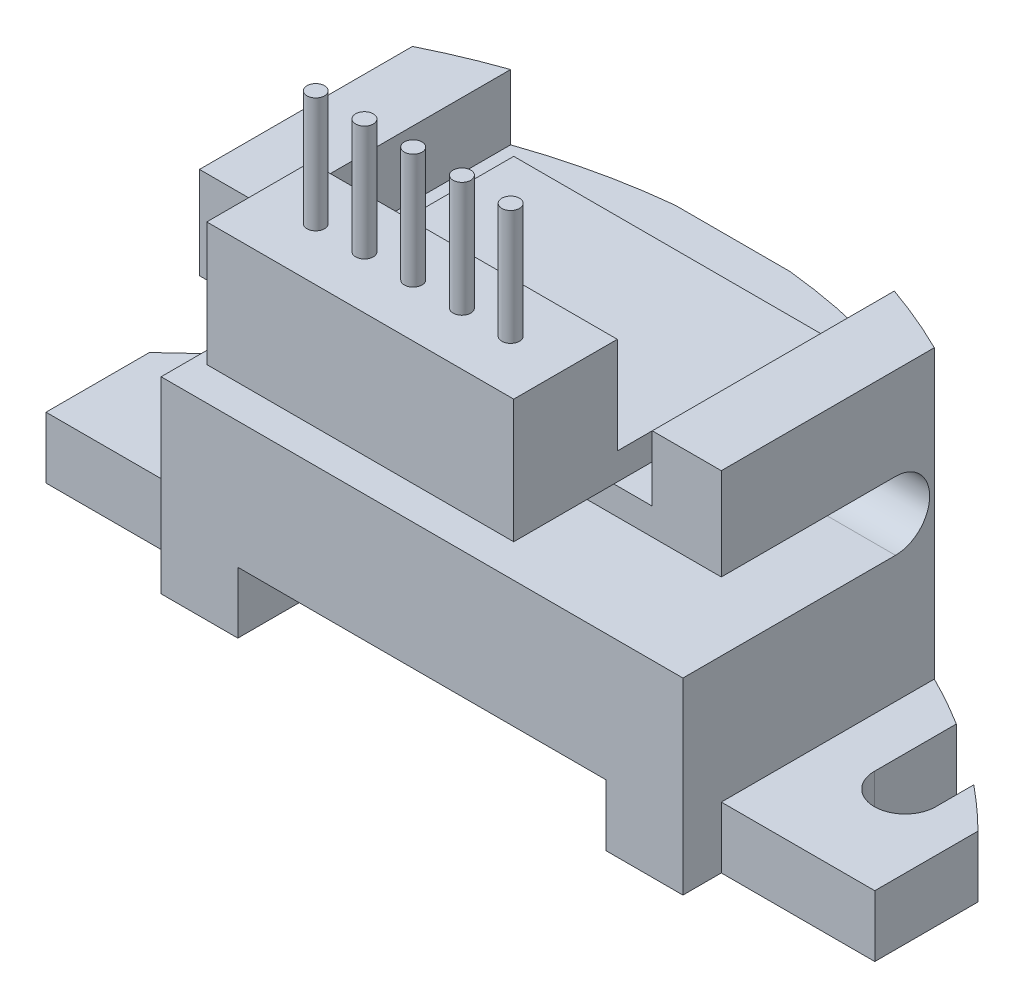
from build123d import *

# Parameters (mm, degrees)
BOSS_EXTRUDE1_DEPTH = 1.6
BOSS_EXTRUDE2_DEPTH = 1.6
BOSS_EXTRUDE3_DEPTH = 3.3
BOSS_EXTRUDE4_DEPTH = 1
BOSS_EXTRUDE5_DEPTH = 6.8
SKETCH7_W           = 1.5
SKETCH7_H           = 1.538953592
BOSS_EXTRUDE6_DEPTH = 4.18
SKETCH8_R           = 1
BOSS_EXTRUDE7_DEPTH = 0.8
SKETCH9_W           = 5
SKETCH9_H           = 1.7
CUT_EXTRUDE1_DEPTH  = 8.09
BOSS_EXTRUDE8_DEPTH = 4
SKETCH12_R          = 0.23
BOSS_EXTRUDE9_DEPTH = 3


with BuildPart() as part:
    # Sketch1 → Boss-Extrude1 (new body)
    with BuildSketch(Plane(origin=(0, 0, 0), x_dir=(1, 0, 0), z_dir=(0, 1, 0))):
        with BuildLine():
            Line((9.7, 0), (9.7, 0.989309127))
            ThreePointArc((9.7, 0.989309127), (10.261810116, 0.507786079), (10.8, 0))
            Line((10.8, 0), (10.8, -2.69))
            Line((10.8, -2.69), (6.8, -2.69))
            Line((6.8, -2.69), (6.8, 2.861046408))
            ThreePointArc((6.8, 2.861046408), (7.458731009, 2.513392708), (8.1, 2.134494679))
            Line((8.1, 2.134494679), (8.1, 0))
            ThreePointArc((8.1, 0), (8.9, -0.8), (9.7, 0))
        make_face()
    extrude(amount=BOSS_EXTRUDE1_DEPTH)

    # Sketch2 → Boss-Extrude2 (add)
    with BuildSketch(Plane(origin=(0, 1.6, 0), x_dir=(1, 0, 0), z_dir=(0, 1, 0))):
        with BuildLine():
            Line((6.8, -2.69), (6.8, 2.861046408))
            ThreePointArc((6.8, 2.861046408), (5.814434387, 3.309058403), (4.8, 3.687181666))
            Line((4.8, 3.687181666), (4.8, -2.69))
            Line((4.8, -2.69), (6.8, -2.69))
        make_face()
    extrude(amount=-BOSS_EXTRUDE2_DEPTH)

    # Sketch3 → Boss-Extrude3 (add)
    with BuildSketch(Plane(origin=(0, 1.6, 0), x_dir=(1, 0, 0), z_dir=(0, 1, 0))):
        with BuildLine():
            Line((6.8, -2.69), (6.8, 2.861046408))
            ThreePointArc((6.8, 2.861046408), (4.219046242, 3.868311453), (1.5, 4.4))
            Line((1.5, 4.4), (1.5, 1.9))
            Line((1.5, 1.9), (0, 1.9))
            Line((0, 1.9), (0, -2.69))
            Line((0, -2.69), (6.8, -2.69))
        make_face()
    extrude(amount=BOSS_EXTRUDE3_DEPTH)

    # Sketch4 → Boss-Extrude4 (add)
    with BuildSketch(Plane.XY.offset(2.69)):
        Polygon((6.8, 1.6), (6.8, 0), (4.8, 0), (4.8, 1.6), (0, 1.6), (0, 4.9), (6.8, 4.9), align=None)
    extrude(amount=BOSS_EXTRUDE4_DEPTH)

    # Sketch6 → Boss-Extrude5 (add)
    with BuildSketch(Plane(origin=(6.8, 0, 0), x_dir=(0, 0, -1), z_dir=(1, 0, 0))):
        with BuildLine():
            Line((-2.69, 9.08), (2.861046408, 9.08))
            Line((2.861046408, 9.08), (2.861046408, 4.9))
            Line((2.861046408, 4.9), (1.85, 4.9))
            ThreePointArc((1.85, 4.9), (2.74, 5.79), (1.85, 6.68))
            Line((1.85, 6.68), (-2.69, 6.68))
            Line((-2.69, 6.68), (-2.69, 9.08))
        make_face()
    extrude(amount=-BOSS_EXTRUDE5_DEPTH)

    # Sketch7 → Boss-Extrude6 (add)
    with BuildSketch(Plane(origin=(0, 4.9, 0), x_dir=(1, 0, 0), z_dir=(0, 1, 0))):
        with Locations((0.75, 3.630523204)):
            Rectangle(SKETCH7_W, SKETCH7_H)
        with BuildLine():
            Line((1.5, 4.4), (1.5, 2.861046408))
            Line((1.5, 2.861046408), (6.8, 2.861046408))
            ThreePointArc((6.8, 2.861046408), (4.219046242, 3.868311453), (1.5, 4.4))
        make_face()
    extrude(amount=BOSS_EXTRUDE6_DEPTH)

    # Sketch8 → Boss-Extrude7 (add)
    with BuildSketch(Plane.XZ):
        with Locations((6.3, 0)):
            Circle(SKETCH8_R)
    extrude(amount=BOSS_EXTRUDE7_DEPTH)

    # Sketch9 → Cut-Extrude1 (cut, through all)
    with BuildSketch(Plane.XY.offset(2.69)):
        with Locations((2.5, 8.23)):
            Rectangle(SKETCH9_W, SKETCH9_H)
    extrude(amount=-CUT_EXTRUDE1_DEPTH, mode=Mode.SUBTRACT)

    # Mirror3: part across plane


with BuildPart() as part_1:
    add(part.part)
    add(part.part.mirror(Plane(origin=(0, 4.9, -1.9), x_dir=(0, 0, 1), z_dir=(1, 0, 0))))

    # Sketch10 → Boss-Extrude8 (add, symmetric)
    with BuildSketch(Plane(origin=(0, 0, 0), x_dir=(0, 0, -1), z_dir=(1, 0, 0))):
        Polygon((0, 7.38), (-5.3, 7.38), (-5.3, 10.6), (-2.6, 10.6), (-2.6, 8.08), (0, 8.08), (2.7, 8.08), (2.7, 7.38), align=None)
    extrude(amount=BOSS_EXTRUDE8_DEPTH, both=True)

    # Sketch12 → Boss-Extrude9 (add)
    with BuildSketch(Plane(origin=(0, 10.6, 0), x_dir=(1, 0, 0), z_dir=(0, 1, 0))):
        with Locations((0, -3.92)):
            Circle(SKETCH12_R)
        with Locations((1.27, -3.92)):
            Circle(SKETCH12_R)
        with Locations((2.54, -3.92)):
            Circle(SKETCH12_R)
        with Locations((-1.27, -3.92)):
            Circle(SKETCH12_R)
        with Locations((-2.54, -3.92)):
            Circle(SKETCH12_R)
    extrude(amount=BOSS_EXTRUDE9_DEPTH)


solid = part_1.part
